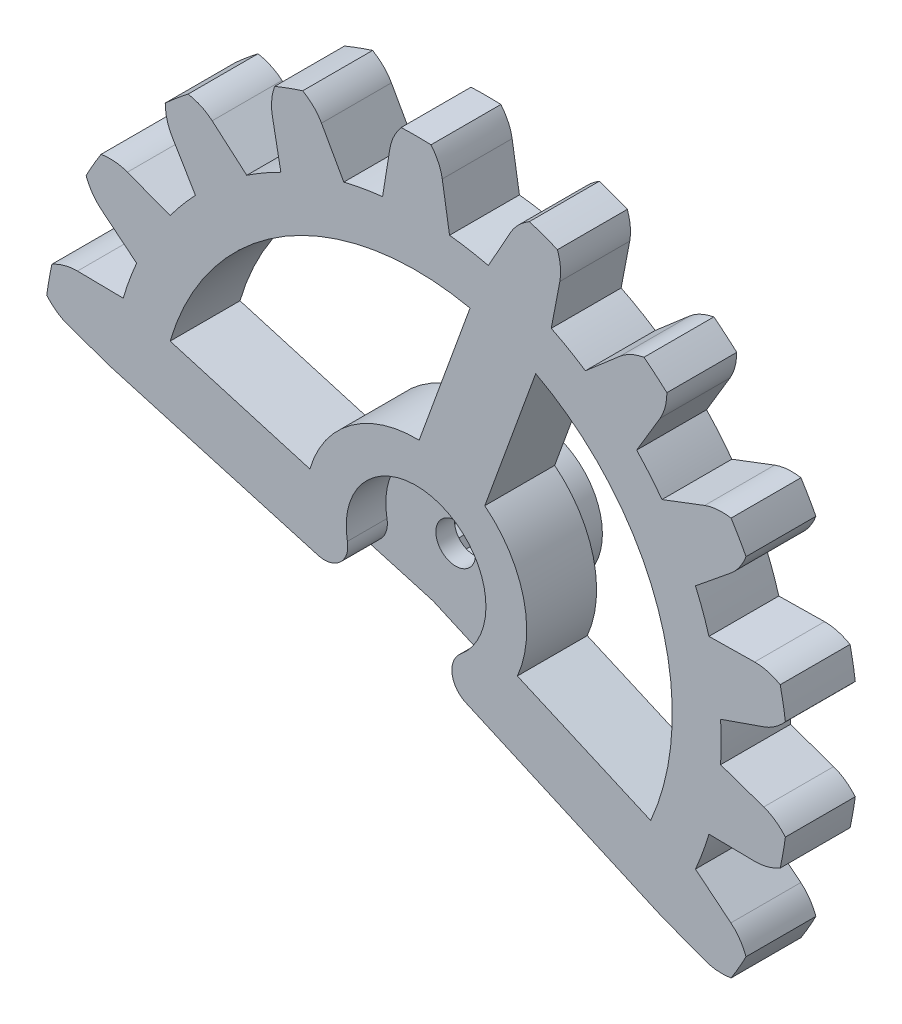
from build123d import *

# Parameters (mm, degrees)
BOSS_EXTRUDE3_START = 2.7
SKETCH2_4_R         = 2.15
SKETCH2_4_R_2       = 0.85
BOSS_EXTRUDE3_DEPTH = 2.5
SKETCH2_R           = 2.8
BOSS_EXTRUDE4_DEPTH = 5.2
BOSS_EXTRUDE5_DEPTH = 3
CIRPATTERN1_COUNT   = 18
CUT_EXTRUDE3_DEPTH  = 3
SKETCH5_R           = 3
CUT_EXTRUDE4_DEPTH  = 1.7
CUT_EXTRUDE5_DEPTH  = 10
FILLET1_R           = 1


with BuildPart() as part:
    # Sketch2_4 → Boss-Extrude3 (new body)
    with BuildSketch(Plane.XY.offset(BOSS_EXTRUDE3_START)):
        Circle(SKETCH2_4_R)
        Circle(SKETCH2_4_R_2, mode=Mode.SUBTRACT)
    extrude(amount=BOSS_EXTRUDE3_DEPTH)

    # Sketch2 → Boss-Extrude4 (add)
    with BuildSketch(Plane.XY):
        Circle(SKETCH2_R)
        Polygon((0, 2), (0.374241043, 1.760665681), (0.813473286, 1.827090915), (1.058013454, 1.45623059), (1.486289651, 1.338261213), (1.558845727, 0.9), (1.902113033, 0.618033989), (1.790139412, 0.188151234), (1.989043791, -0.209056927), (1.711901729, -0.55623059), (1.732050808, -1), (1.337660686, -1.204435091), (1.175570505, -1.618033989), (0.732125958, -1.644381824), (0.415823382, -1.956295201), (0, -1.8), (-0.415823382, -1.956295201), (-0.732125958, -1.644381824), (-1.175570505, -1.618033989), (-1.337660686, -1.204435091), (-1.732050808, -1), (-1.711901729, -0.55623059), (-1.989043791, -0.209056927), (-1.790139412, 0.188151234), (-1.902113033, 0.618033989), (-1.558845727, 0.9), (-1.486289651, 1.338261213), (-1.058013454, 1.45623059), (-0.813473286, 1.827090915), (-0.374241043, 1.760665681), align=None, mode=Mode.SUBTRACT)
    extrude(amount=BOSS_EXTRUDE4_DEPTH)


with BuildPart() as body_2:
    # Sketch3 → Boss-Extrude5 (new body)
    with BuildSketch(Plane.XY.offset(5.2)):
        with BuildLine():
            ThreePointArc((13.1, 0), (13.09317187, 0.422907051), (13.072694599, 0.845373238))
            Line((13.072694599, 0.845373238), (14.925833549, 1.489796246))
            add(Edge.make_bspline(
                [(14.925833549, 1.489796246), (15.441491389, 1.669114573), (15.855731195, 2.143778967)],
                knots=[0, 0, 0, 1, 1, 1], degree=2))
            ThreePointArc((15.855731195, 2.143778967), (15.756924048, 2.778370843), (15.632729191, 3.40848618))
            add(Edge.make_bspline(
                [(14.535235971, 3.704985191), (15.081126317, 3.71284645), (15.632729191, 3.40848618)],
                knots=[0, 0, 0, 1, 1, 1], degree=2))
            Line((14.535235971, 3.704985191), (12.573449325, 3.676733887))
            ThreePointArc((12.573449325, 3.676733887), (12.44819972, 4.080725884), (12.309973332, 4.480463878))
            Line((12.309973332, 4.480463878), (2.631139338, 0.957656401))
            ThreePointArc((2.631139338, 0.957656401), (2.757461708, 0.486214897), (2.8, 0))
            Line((2.8, 0), (13.1, 0))
        make_face()
    extrude(amount=-BOSS_EXTRUDE5_DEPTH)


with BuildPart() as cirpattern1_1:
    # CirPattern1: pattern copy
    add(body_2.part.rotate(Axis((0, 0, 5.2), (0, 0, 1)), 1 * 360 / CIRPATTERN1_COUNT))


with BuildPart() as cirpattern1_2:
    # CirPattern1: pattern copy
    add(body_2.part.rotate(Axis((0, 0, 5.2), (0, 0, 1)), 2 * 360 / CIRPATTERN1_COUNT))


with BuildPart() as cirpattern1_3:
    # CirPattern1: pattern copy
    add(body_2.part.rotate(Axis((0, 0, 5.2), (0, 0, 1)), 3 * 360 / CIRPATTERN1_COUNT))


with BuildPart() as cirpattern1_4:
    # CirPattern1: pattern copy
    add(body_2.part.rotate(Axis((0, 0, 5.2), (0, 0, 1)), 4 * 360 / CIRPATTERN1_COUNT))


with BuildPart() as cirpattern1_5:
    # CirPattern1: pattern copy
    add(body_2.part.rotate(Axis((0, 0, 5.2), (0, 0, 1)), 5 * 360 / CIRPATTERN1_COUNT))


with BuildPart() as cirpattern1_6:
    # CirPattern1: pattern copy
    add(body_2.part.rotate(Axis((0, 0, 5.2), (0, 0, 1)), 6 * 360 / CIRPATTERN1_COUNT))


with BuildPart() as cirpattern1_7:
    # CirPattern1: pattern copy
    add(body_2.part.rotate(Axis((0, 0, 5.2), (0, 0, 1)), 7 * 360 / CIRPATTERN1_COUNT))


with BuildPart() as cirpattern1_8:
    # CirPattern1: pattern copy
    add(body_2.part.rotate(Axis((0, 0, 5.2), (0, 0, 1)), 8 * 360 / CIRPATTERN1_COUNT))


with BuildPart() as cirpattern1_9:
    # CirPattern1: pattern copy
    add(body_2.part.rotate(Axis((0, 0, 5.2), (0, 0, 1)), 9 * 360 / CIRPATTERN1_COUNT))


with BuildPart() as cirpattern1_10:
    # CirPattern1: pattern copy
    add(body_2.part.rotate(Axis((0, 0, 5.2), (0, 0, 1)), 10 * 360 / CIRPATTERN1_COUNT))


with BuildPart() as cirpattern1_11:
    # CirPattern1: pattern copy
    add(body_2.part.rotate(Axis((0, 0, 5.2), (0, 0, 1)), 11 * 360 / CIRPATTERN1_COUNT))


with BuildPart() as cirpattern1_12:
    # CirPattern1: pattern copy
    add(body_2.part.rotate(Axis((0, 0, 5.2), (0, 0, 1)), 12 * 360 / CIRPATTERN1_COUNT))


with BuildPart() as cirpattern1_13:
    # CirPattern1: pattern copy
    add(body_2.part.rotate(Axis((0, 0, 5.2), (0, 0, 1)), 13 * 360 / CIRPATTERN1_COUNT))


with BuildPart() as cirpattern1_14:
    # CirPattern1: pattern copy
    add(body_2.part.rotate(Axis((0, 0, 5.2), (0, 0, 1)), 14 * 360 / CIRPATTERN1_COUNT))


with BuildPart() as cirpattern1_15:
    # CirPattern1: pattern copy
    add(body_2.part.rotate(Axis((0, 0, 5.2), (0, 0, 1)), 15 * 360 / CIRPATTERN1_COUNT))


with BuildPart() as cirpattern1_16:
    # CirPattern1: pattern copy
    add(body_2.part.rotate(Axis((0, 0, 5.2), (0, 0, 1)), 16 * 360 / CIRPATTERN1_COUNT))


with BuildPart() as cirpattern1_17:
    # CirPattern1: pattern copy
    add(body_2.part.rotate(Axis((0, 0, 5.2), (0, 0, 1)), 17 * 360 / CIRPATTERN1_COUNT))


with BuildPart() as cirpattern1_6_1:
    add(cirpattern1_6.part)

    # Combine1: union CirPattern1_5, CirPattern1_4, CirPattern1_3, CirPattern1_2, CirPattern1_1, body 2, CirPattern1_17, CirPattern1_16, CirPattern1_15, CirPattern1_14, CirPattern1_13, CirPattern1_12, CirPattern1_11, CirPattern1_10, CirPattern1_9, CirPattern1_8, CirPattern1_7
    add(cirpattern1_5.part)
    add(cirpattern1_4.part)
    add(cirpattern1_3.part)
    add(cirpattern1_2.part)
    add(cirpattern1_1.part)
    add(body_2.part)
    add(cirpattern1_17.part)
    add(cirpattern1_16.part)
    add(cirpattern1_15.part)
    add(cirpattern1_14.part)
    add(cirpattern1_13.part)
    add(cirpattern1_12.part)
    add(cirpattern1_11.part)
    add(cirpattern1_10.part)
    add(cirpattern1_9.part)
    add(cirpattern1_8.part)
    add(cirpattern1_7.part)

    # Combine2: union part
    add(part.part)

    # Sketch4 → Cut-Extrude3 (cut)
    with BuildSketch(Plane.XY.offset(5.2)):
        with BuildLine():
            Line((-13.072694599, 0.845373238), (-0.957656401, -2.631139338))
            Line((-0.957656401, -2.631139338), (10.557660497, -7.755372642))
            Line((10.557660497, -7.755372642), (13.350884375, -8.81781642))
            ThreePointArc((13.350884375, -8.81781642), (-5.472322293, -15.035081933), (-15.895353925, 1.826943785))
            Line((-15.895353925, 1.826943785), (-13.072694599, 0.845373238))
        make_face()
    extrude(amount=-CUT_EXTRUDE3_DEPTH, mode=Mode.SUBTRACT)

    # Sketch5 → Cut-Extrude4 (cut)
    with BuildSketch(Plane.XY.offset(5.2)):
        Circle(SKETCH5_R)
    extrude(amount=-CUT_EXTRUDE4_DEPTH, mode=Mode.SUBTRACT)

    # Sketch6 → Cut-Extrude5 (cut)
    with BuildSketch(Plane.XY.offset(5.2)):
        with BuildLine():
            Line((2.317539172, 10.753093145), (0.131925024, 4.748167624))
            ThreePointArc((0.131925024, 4.748167624), (-2.795616582, 3.840185923), (-4.559075137, 1.333166867))
            Line((-4.559075137, 1.333166867), (-10.557858212, 3.087333798))
            ThreePointArc((-10.557858212, 3.087333798), (-5.627315617, 9.451630491), (2.317539172, 10.753093145))
        make_face()
        with BuildLine():
            ThreePointArc((5.136617035, 9.727032715), (10.386164829, 3.623200261), (10.072288527, -4.421425543))
            Line((10.072288527, -4.421425543), (4.349397318, -1.909251939))
            ThreePointArc((4.349397318, -1.909251939), (4.609990478, 1.144765387), (2.951002886, 3.722107194))
            Line((2.951002886, 3.722107194), (5.136617035, 9.727032715))
        make_face()
    extrude(amount=-CUT_EXTRUDE5_DEPTH, mode=Mode.SUBTRACT)

    # Fillet1
    fillet1_edges = [cirpattern1_6_1.edges().sort_by_distance(p)[0] for p in [
        (-0.135636671, -2.996932214, 4.35),
        (-1.822487176, -2.38296884, 4.35),
    ]]
    fillet(fillet1_edges, radius=FILLET1_R)


solid = cirpattern1_6_1.part
